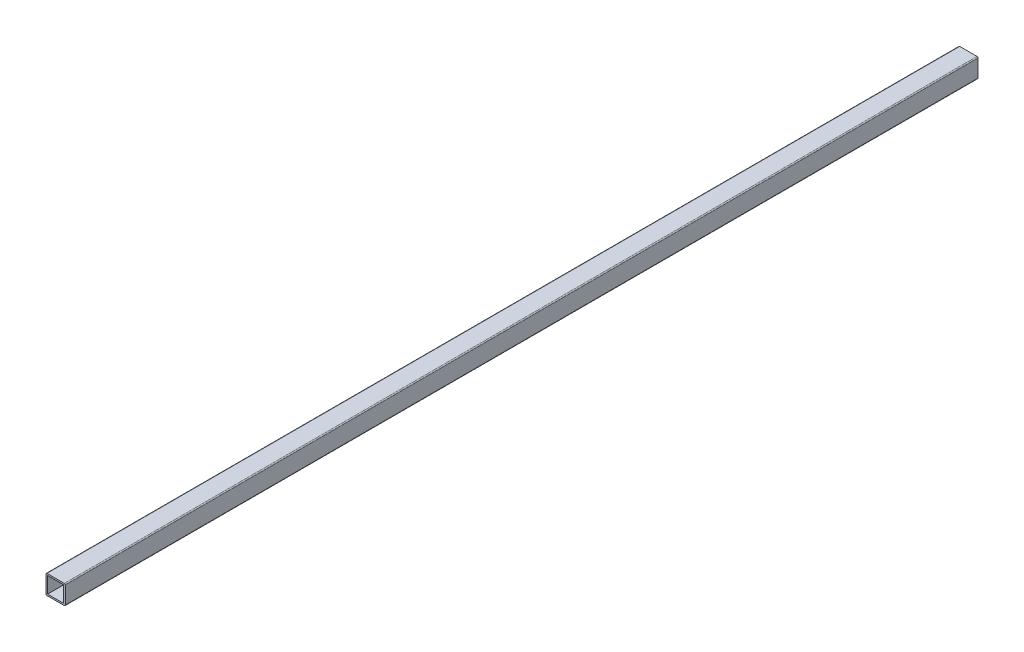
from build123d import *

# Parameters (mm, degrees)
SKETCH_1_W      = 19
SKETCH_1_H      = 19
SKETCH_1_W_2    = 15.88
SKETCH_1_H_2    = 15.88
EXTRUDE_1_DEPTH = 900
FILLET_2_R      = 1


with BuildPart() as part:
    # 스케치1 → 보스-돌출1 (new body)
    with BuildSketch(Plane.XY):
        with Locations((9.5, -9.5)):
            Rectangle(SKETCH_1_W, SKETCH_1_H)
        with Locations((9.5, -9.5)):
            Rectangle(SKETCH_1_W_2, SKETCH_1_H_2, mode=Mode.SUBTRACT)
    extrude(amount=EXTRUDE_1_DEPTH)

    # 필렛2
    fillet_2_edges = [part.edges().sort_by_distance(p)[0] for p in [
        (0, 0, 450),
        (19, 0, 450),
        (19, -19, 450),
        (0, -19, 450),
    ]]
    fillet(fillet_2_edges, radius=FILLET_2_R)


solid = part.part
